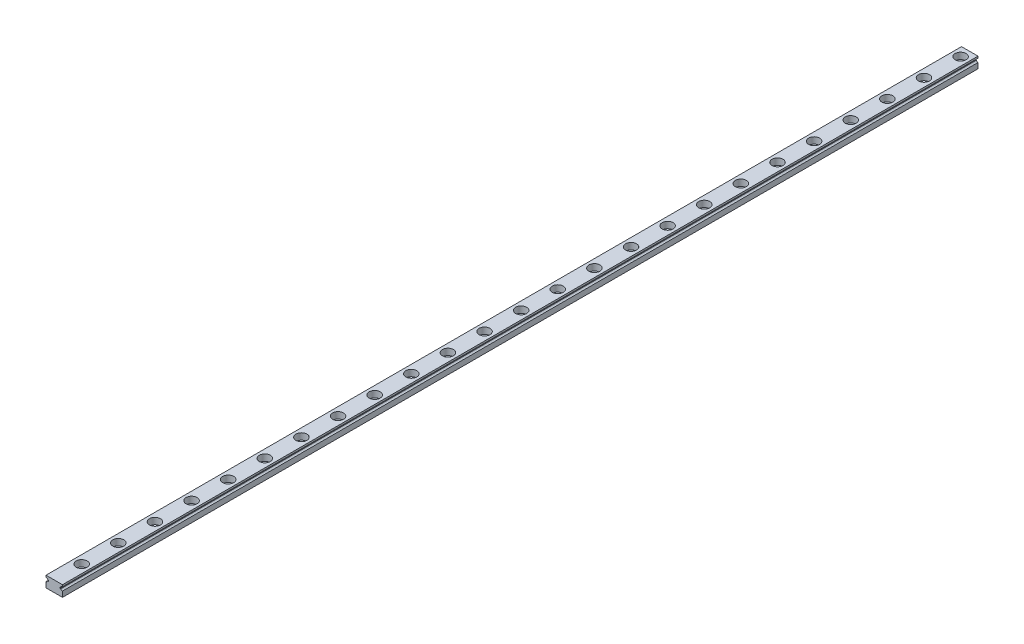
from build123d import *

# Parameters (mm, degrees)
EXTRUDE1_DEPTH  = 500
SKETCH2_R       = 3
EXTRUDE2_DEPTH  = 3.5
SKETCH_R        = 1.75
EXTRUDE3_DEPTH  = 501.056246836
LPATTERN1_COUNT = 30
LPATTERN1_PITCH = 20


with BuildPart() as part:
    # Sketch1 → Extrude1 (new body)
    with BuildSketch(Plane.XY):
        with BuildLine():
            Line((-4.5, -3), (4.5, -3))
            Line((4.5, -3), (4.5, 0))
            ThreePointArc((4.5, 0), (3.93077967, 0.177814974), (3.563991137, 0.648023568))
            Line((3.563991137, 0.648023568), (3.235073025, 0.648023568))
            Line((3.235073025, 0.648023568), (3.235073025, 1.351976432))
            Line((3.235073025, 1.351976432), (3.563991137, 1.351976432))
            ThreePointArc((3.563991137, 1.351976432), (3.93077967, 1.822185026), (4.5, 2))
            Line((4.5, 2), (4.5, 3))
            Line((4.5, 3), (-4.5, 3))
            Line((-4.5, 3), (-4.5, 2))
            ThreePointArc((-4.5, 2), (-3.93077967, 1.822185026), (-3.563991137, 1.351976432))
            Line((-3.563991137, 1.351976432), (-3.235073025, 1.351976432))
            Line((-3.235073025, 1.351976432), (-3.235073025, 0.648023568))
            Line((-3.235073025, 0.648023568), (-3.563991137, 0.648023568))
            ThreePointArc((-3.563991137, 0.648023568), (-3.93077967, 0.177814974), (-4.5, 0))
            Line((-4.5, 0), (-4.5, -3))
        make_face()
    extrude(amount=EXTRUDE1_DEPTH)

    # Sketch2 → Extrude2 (cut)
    with BuildSketch(Plane(origin=(0, 3, 0), x_dir=(1, 0, 0), z_dir=(0, 1, 0))):
        with Locations((0, -5)):
            Circle(SKETCH2_R)
    extrude2 = extrude(amount=-EXTRUDE2_DEPTH, mode=Mode.SUBTRACT)

    # Sketch → Extrude3 (cut, through all)
    with BuildSketch(Plane(origin=(0, 3, 0), x_dir=(1, 0, 0), z_dir=(0, 1, 0))):
        with Locations((0, -5)):
            Circle(SKETCH_R)
    extrude3 = extrude(amount=-EXTRUDE3_DEPTH, mode=Mode.SUBTRACT)

    # LPattern1: Extrude2, Extrude3 ×30
    with Locations(*[(0, 0, i * LPATTERN1_PITCH) for i in range(1, LPATTERN1_COUNT)]):
        add(extrude2, mode=Mode.SUBTRACT)
        add(extrude3, mode=Mode.SUBTRACT)


solid = part.part
